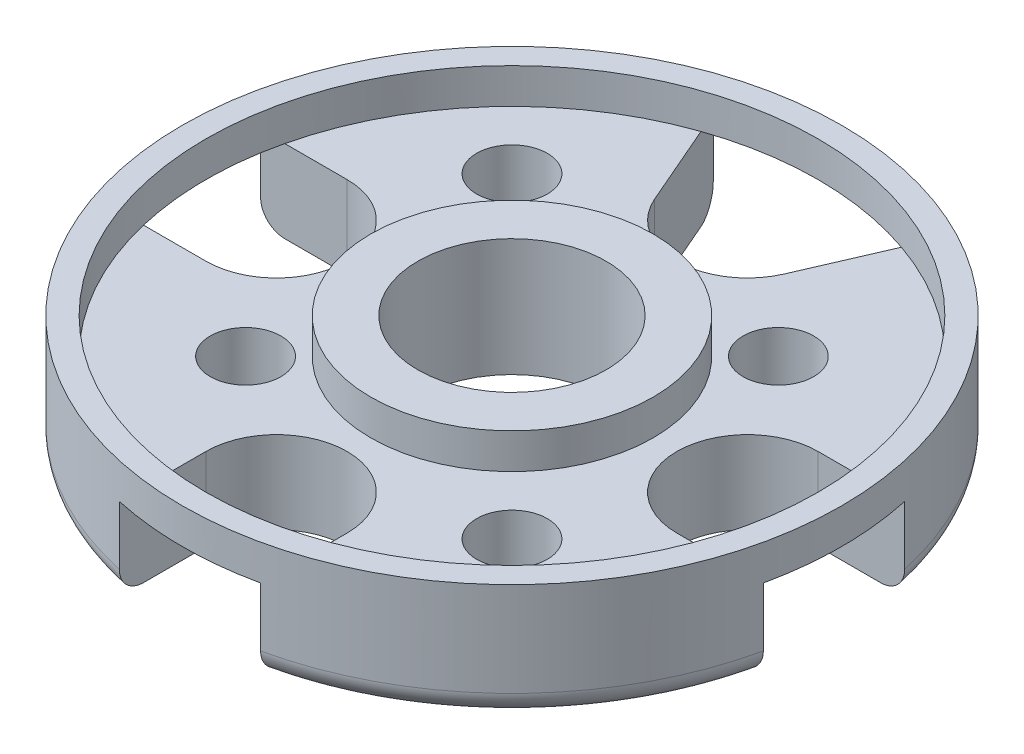
from build123d import *

# Parameters (mm, degrees)
ESQUISSE1_R                  = 14
BASE_BRUT_DEPTH              = 5
CONG_1_R                     = 1
ESQUISSE2_R                  = 13
CREUX_INTERIEUR_DEPTH        = 1.5
CREUSEMENT_EXTERIEUR_REACH   = 22.421
R_P_TITION_CIRCULAIRE1_COUNT = 3
R_P_TITION_CIRCULAIRE1_ANGLE = 180
PASSAGE_FILS_REACH           = 22.421
ESQUISSE5_R                  = 4
PASSAGE_AXE_ROTOR_DEPTH      = 21.10596928
ESQUISSE6_R                  = 6
ESQUISSE6_R_2                = 4
BOSSAGE_AXE_ROTOR_DEPTH      = 1.5
ESQUISSE7_R                  = 1.5
CUT_EXTRUDE_M3_DEPTH         = 21.420577857


with BuildPart() as part:
    # Esquisse1 → base brut (new body)
    with BuildSketch(Plane(origin=(0, 0, 0), x_dir=(1, 0, 0), z_dir=(0, 1, 0))):
        with Locations(Location((0, 0, 0), (0, 0, 270))):
            Circle(ESQUISSE1_R)
    extrude(amount=BASE_BRUT_DEPTH)

    # Congé1
    cong_1_edges = [part.edges().sort_by_distance(p)[0] for p in [
        (0, 0, -14),
    ]]
    fillet(cong_1_edges, radius=CONG_1_R)

    # Esquisse2 → creux interieur (cut)
    with BuildSketch(Plane(origin=(0, 5, 0), x_dir=(1, 0, 0), z_dir=(0, 1, 0))):
        with Locations(Location((0, 0, 0), (0, 0, 270))):
            Circle(ESQUISSE2_R)
    extrude(amount=-CREUX_INTERIEUR_DEPTH, mode=Mode.SUBTRACT)

    # creusement exterieur: up to this face of the body (flat: up to its plane)
    creusement_exterieur_end = Plane(part.part.faces().sort_by_distance((0, 3.5, 0))[0])
    # Esquisse3 → creusement exterieur (cut, up to the picked face)
    with BuildSketch(Plane.XZ, mode=Mode.PRIVATE) as creusement_exterieur_sk1:
        with BuildLine():
            Line((10, 3), (14, 3))
            Line((14, 3), (14, -3))
            Line((14, -3), (10, -3))
            ThreePointArc((10, -3), (7.000000123, 0), (10, 3))
        make_face()
    creusement_exterieur_tool1 = split(extrude(creusement_exterieur_sk1.sketch, amount=-CREUSEMENT_EXTERIEUR_REACH, mode=Mode.PRIVATE), bisect_by=creusement_exterieur_end, keep=Keep.BOTH, mode=Mode.PRIVATE)
    creusement_exterieur = creusement_exterieur_tool1.solids().sort_by(Axis((10.786634, 0, 0), (0, 1, 0)))[0]
    add(creusement_exterieur, mode=Mode.SUBTRACT)

    # Répétition circulaire1: creusement exterieur ×3 about axis
    r_p_tition_circulaire1_axis = Axis((0, 0, 0), (0, -1, 0))
    for i in range(1, R_P_TITION_CIRCULAIRE1_COUNT):
        add(creusement_exterieur.rotate(r_p_tition_circulaire1_axis, i * R_P_TITION_CIRCULAIRE1_ANGLE / (R_P_TITION_CIRCULAIRE1_COUNT - 1)), mode=Mode.SUBTRACT)

    # passage fils: up to this face of the body (flat: up to its plane)
    passage_fils_end = Plane(part.part.faces().sort_by_distance((0, 3.5, -0.736058637))[0])
    # Esquisse4 → passage fils (cut, up to the picked face)
    with BuildSketch(Plane.XZ, mode=Mode.PRIVATE) as passage_fils_sk1:
        with BuildLine():
            Line((-5, -14), (5, -14))
            Line((5, -14), (2.753225624, -8.808468057))
            ThreePointArc((2.753225624, -8.808468057), (0, -7.000000123), (-2.753225624, -8.808468057))
            Line((-2.753225624, -8.808468057), (-5, -14))
        make_face()
    passage_fils_tool1 = split(extrude(passage_fils_sk1.sketch, amount=-PASSAGE_FILS_REACH, mode=Mode.PRIVATE), bisect_by=passage_fils_end, keep=Keep.BOTH, mode=Mode.PRIVATE)
    add(passage_fils_tool1.solids().sort_by(Axis((0, 0, -11.111092), (0, 1, 0)))[0], mode=Mode.SUBTRACT)

    # Esquisse5 → passage axe rotor (cut, through all)
    with BuildSketch(Plane(origin=(0, 3.5, 0), x_dir=(-1, 0, 0), z_dir=(0, 1, 0))):
        with Locations(Location((0, 0, 0), (0, 0, 90))):
            Circle(ESQUISSE5_R)
    extrude(amount=-PASSAGE_AXE_ROTOR_DEPTH, mode=Mode.SUBTRACT)

    # Esquisse6 → bossage axe rotor (add)
    with BuildSketch(Plane(origin=(0, 3.5, 0), x_dir=(1, 0, 0), z_dir=(0, 1, 0))):
        with Locations(Location((0, 0, 0), (0, 0, 270))):
            Circle(ESQUISSE6_R)
        with Locations(Location((0, 0, 0), (0, 0, 270))):
            Circle(ESQUISSE6_R_2, mode=Mode.SUBTRACT)
    extrude(amount=BOSSAGE_AXE_ROTOR_DEPTH)

    # Esquisse7 → M3 (cut, through all)
    with BuildSketch(Plane.XZ):
        with Locations(Location((-5.656854249, 5.656854249, 0), (0, 0, 270))):
            Circle(ESQUISSE7_R)
        with Locations(Location((5.656854249, -5.656854249, 0), (0, 0, 270))):
            Circle(ESQUISSE7_R)
        with Locations(Location((6.717514421, 6.717514421, 0), (0, 0, 270))):
            Circle(ESQUISSE7_R)
        with Locations(Location((-6.717514421, -6.717514421, 0), (0, 0, 270))):
            Circle(ESQUISSE7_R)
    extrude(amount=-CUT_EXTRUDE_M3_DEPTH, mode=Mode.SUBTRACT)


solid = part.part
